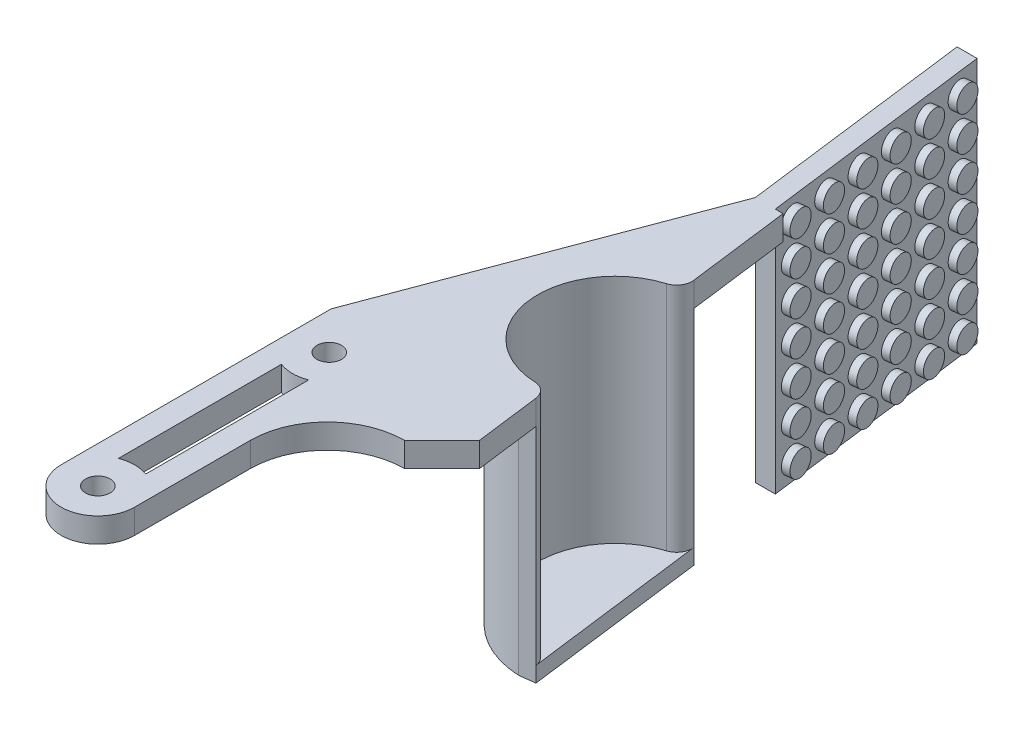
from build123d import *
from build123d.topology import SkipClean

# Parameters (mm, degrees)
CROQUIS1_R              = 1.5875
SALIENTE_EXTRUIR1_DEPTH = 3.175
CORTAR_EXTRUIR1_DEPTH   = 3.175
CORTAR_EXTRUIR3_DEPTH   = 10
CROQUIS5_R              = 10
CORTAR_EXTRUIR8_DEPTH   = 10
REDONDEO2_R             = 2
BOSS_EXTRUDE1_DEPTH     = 30
BOSS_EXTRUDE2_DEPTH     = 2
BOSS_EXTRUDE3_DEPTH     = 32
SKETCH6_R               = 1.59
BOSS_EXTRUDE5_DEPTH     = 1


with BuildPart() as part:
    # Croquis1 → Saliente-Extruir1 (new body)
    with BuildSketch(Plane(origin=(0, 0, 0), x_dir=(1, 0, 0), z_dir=(0, 1, 0))):
        with BuildLine():
            Line((-12.5, 0), (-12.5, -40))
            Line((-12.5, -40), (-2.975, -40))
            Line((-2.975, -40), (-2.975, -20))
            ThreePointArc((-2.975, -20), (-0.046067812, -12.928932188), (7.025, -10))
            Line((7.025, -10), (12.5, -10))
            Line((12.5, -10), (12.5, 40))
            Line((12.5, 40), (2.5, 40))
            Line((2.5, 40), (-12.5, 0))
        make_face()
        with Locations(Location((-7.7375, -5, 0), (0, 0, 270))):
            Circle(CROQUIS1_R, mode=Mode.SUBTRACT)
        with Locations(Location((-7.7375, -35, 0), (0, 0, 270))):
            Circle(CROQUIS1_R, mode=Mode.SUBTRACT)
    extrude(amount=SALIENTE_EXTRUIR1_DEPTH)

    # Croquis2 → Cortar-Extruir1 (cut)
    with BuildSketch(Plane(origin=(0, 3.175, 0), x_dir=(1, 0, 0), z_dir=(0, 1, 0))):
        Polygon((12.5, -10), (6.1, 40), (12.5, 40), align=None)
    extrude(amount=-CORTAR_EXTRUIR1_DEPTH, mode=Mode.SUBTRACT)

    # Croquis3 → Cortar-Extruir3 (cut)
    with BuildSketch(Plane(origin=(0, 3.175, 0), x_dir=(1, 0, 0), z_dir=(0, 1, 0))):
        with BuildLine():
            ThreePointArc((-5.975, -30.575635639), (-7.7375, -30.2375), (-9.5, -30.575635639))
            Line((-9.5, -30.575635639), (-9.5, -9.427055314))
            ThreePointArc((-9.5, -9.427055314), (-7.7375, -9.765), (-5.975, -9.427055314))
            Line((-5.975, -9.427055314), (-5.975, -14.803847577))
            Line((-5.975, -14.803847577), (-5.975, -30.575635639))
        make_face()
        with BuildLine():
            ThreePointArc((-12.5, -35), (-7.7375, -39.7625), (-2.975, -35))
            Line((-2.975, -35), (-2.975, -40))
            Line((-2.975, -40), (-12.5, -40))
            Line((-12.5, -40), (-12.5, -35))
        make_face()
    extrude(amount=-CORTAR_EXTRUIR3_DEPTH, mode=Mode.SUBTRACT)

    # Croquis5 → Cortar-Extruir8 (cut)
    with BuildSketch(Plane(origin=(0, 3.175, 0), x_dir=(1, 0, 0), z_dir=(0, 1, 0))):
        with Locations((9.3, 15)):
            Circle(CROQUIS5_R)
        Polygon((7.025, -10), (11.878723404, -5.146276596), (12.5, -10), align=None)
    extrude(amount=-CORTAR_EXTRUIR8_DEPTH, mode=Mode.SUBTRACT)

    # Redondeo2
    redondeo2_edges = [part.edges().sort_by_distance(p)[0] for p in [
        (8.030358645, 1.5875, -24.919073083),
        (10.569641355, 1.5875, -5.080926917),
    ]]
    fillet(redondeo2_edges, radius=REDONDEO2_R)

    # Sketch1 → Boss-Extrude1 (add)
    with SkipClean():  # the faces are left unmerged after this step: merging them gives an invalid solid
        with BuildSketch(Plane(origin=(0, 3.175, 0), x_dir=(1, 0, 0), z_dir=(0, 1, 0))):
            with BuildLine():
                Line((7.79774009, 26.736405547), (5.813925473, 26.482477276))
                ThreePointArc((5.813925473, 26.482477276), (-2.6028877, 13.476430374), (8.818445293, 3.009666182))
                Line((8.818445293, 3.009666182), (10.80225991, 3.263594453))
                ThreePointArc((10.80225991, 3.263594453), (10.16969874, 4.484153931), (8.898704411, 5.008055152))
                ThreePointArc((8.898704411, 5.008055152), (-0.619073083, 13.730358645), (6.394937894, 24.568731063))
                ThreePointArc((6.394937894, 24.568731063), (7.492998908, 25.395871368), (7.79774009, 26.736405547))
            make_face()
        extrude(amount=-BOSS_EXTRUDE1_DEPTH)

    # Sketch2 → Boss-Extrude2 (add)
    with SkipClean():  # the faces are left unmerged after this step: merging them gives an invalid solid
        with BuildSketch(Plane.XZ.offset(26.825)):
            with BuildLine():
                Line((10.80225991, -3.263594453), (7.79774009, -26.736405547))
                Line((7.79774009, -26.736405547), (5.813925473, -26.482477276))
                ThreePointArc((5.813925473, -26.482477276), (-2.6028877, -13.476430374), (8.818445293, -3.009666182))
                Line((8.818445293, -3.009666182), (10.80225991, -3.263594453))
            make_face()
        extrude(amount=BOSS_EXTRUDE2_DEPTH)

    # Sketch3 → Boss-Extrude3 (add)
    with SkipClean():  # the faces are left unmerged after this step: merging them gives an invalid solid
        with BuildSketch(Plane(origin=(0, 3.175, 0), x_dir=(1, 0, 0), z_dir=(0, 1, 0))):
            Polygon((1.251841282, 70), (-1.34, 70), (2.5, 40), (5.091841282, 40), align=None)
        extrude(amount=-BOSS_EXTRUDE3_DEPTH)

    # Sketch6 → Boss-Extrude5 (add)
    with SkipClean():  # the faces are left unmerged after this step: merging them gives an invalid solid
        with BuildSketch(Plane(origin=(10.047227507, 0, -1.286045121), x_dir=(-0.12696413546540525, 0, -0.9919073083234756), z_dir=(0.9919073083234756, 0, -0.12696413546540525))):
            with Locations((41.529811107, -26.325)):
                Circle(SKETCH6_R)
            with Locations((46.529811107, -26.325)):
                Circle(SKETCH6_R)
            with Locations((51.529811107, -26.325)):
                Circle(SKETCH6_R)
            with Locations((56.529811107, -26.325)):
                Circle(SKETCH6_R)
            with Locations((61.529811107, -26.325)):
                Circle(SKETCH6_R)
            with Locations((66.529811107, -26.325)):
                Circle(SKETCH6_R)
            with Locations((46.529811107, -21.825)):
                Circle(SKETCH6_R)
            with Locations((51.529811107, -21.825)):
                Circle(SKETCH6_R)
            with Locations((56.529811107, -21.825)):
                Circle(SKETCH6_R)
            with Locations((61.529811107, -21.825)):
                Circle(SKETCH6_R)
            with Locations((66.529811107, -21.825)):
                Circle(SKETCH6_R)
            with Locations((46.529811107, -17.325)):
                Circle(SKETCH6_R)
            with Locations((51.529811107, -17.325)):
                Circle(SKETCH6_R)
            with Locations((56.529811107, -17.325)):
                Circle(SKETCH6_R)
            with Locations((61.529811107, -17.325)):
                Circle(SKETCH6_R)
            with Locations((66.529811107, -17.325)):
                Circle(SKETCH6_R)
            with Locations((46.529811107, -12.825)):
                Circle(SKETCH6_R)
            with Locations((51.529811107, -12.825)):
                Circle(SKETCH6_R)
            with Locations((56.529811107, -12.825)):
                Circle(SKETCH6_R)
            with Locations((61.529811107, -12.825)):
                Circle(SKETCH6_R)
            with Locations((66.529811107, -12.825)):
                Circle(SKETCH6_R)
            with Locations((46.529811107, -8.325)):
                Circle(SKETCH6_R)
            with Locations((51.529811107, -8.325)):
                Circle(SKETCH6_R)
            with Locations((56.529811107, -8.325)):
                Circle(SKETCH6_R)
            with Locations((61.529811107, -8.325)):
                Circle(SKETCH6_R)
            with Locations((66.529811107, -8.325)):
                Circle(SKETCH6_R)
            with Locations((46.529811107, -3.825)):
                Circle(SKETCH6_R)
            with Locations((51.529811107, -3.825)):
                Circle(SKETCH6_R)
            with Locations((56.529811107, -3.825)):
                Circle(SKETCH6_R)
            with Locations((61.529811107, -3.825)):
                Circle(SKETCH6_R)
            with Locations((66.529811107, -3.825)):
                Circle(SKETCH6_R)
            with Locations((46.529811107, 0.675)):
                Circle(SKETCH6_R)
            with Locations((51.529811107, 0.675)):
                Circle(SKETCH6_R)
            with Locations((56.529811107, 0.675)):
                Circle(SKETCH6_R)
            with Locations((61.529811107, 0.675)):
                Circle(SKETCH6_R)
            with Locations((66.529811107, 0.675)):
                Circle(SKETCH6_R)
            with Locations((41.529811107, -21.825)):
                Circle(SKETCH6_R)
            with Locations((41.529811107, -17.325)):
                Circle(SKETCH6_R)
            with Locations((41.529811107, -12.825)):
                Circle(SKETCH6_R)
            with Locations((41.529811107, -8.325)):
                Circle(SKETCH6_R)
            with Locations((41.529811107, -3.825)):
                Circle(SKETCH6_R)
            with Locations((41.529811107, 0.675)):
                Circle(SKETCH6_R)
        extrude(amount=BOSS_EXTRUDE5_DEPTH)


solid = part.part
